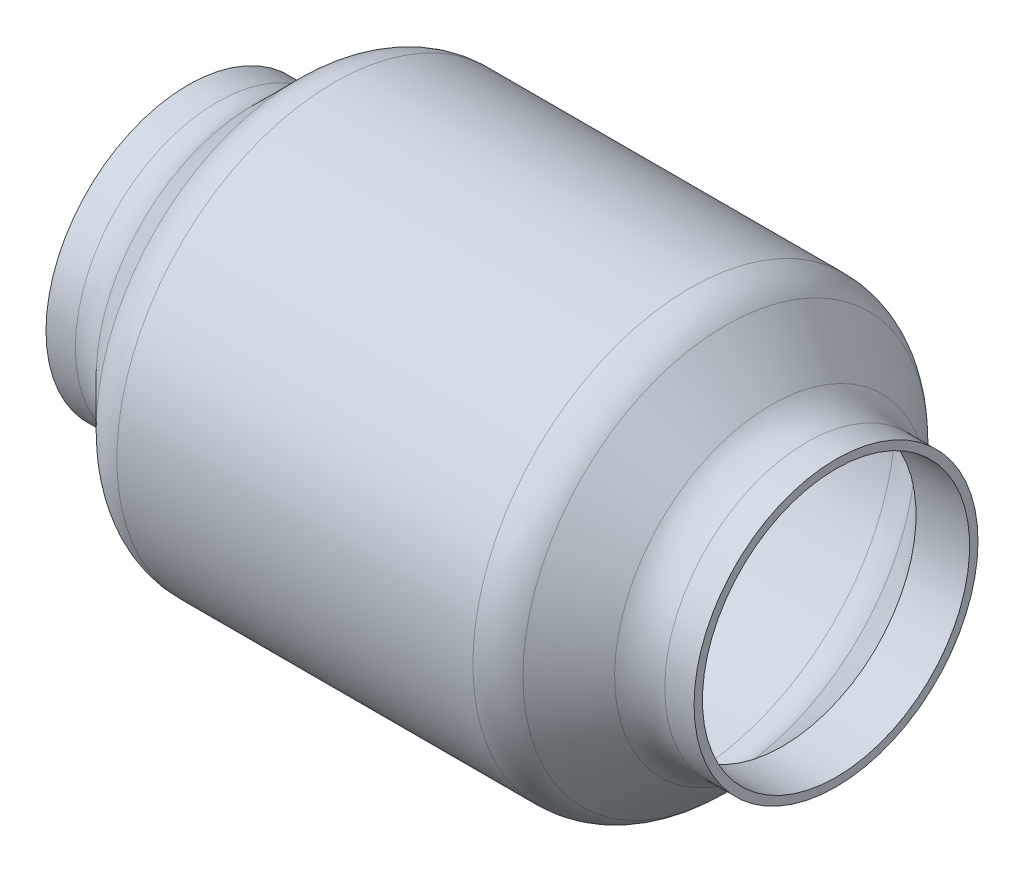
from build123d import *


with BuildPart() as part:
    # Sketch1 → Revolve1 (revolve)
    with BuildSketch(Plane.XY):
        with BuildLine():
            Line((-123.19, 53.975), (-123.19, 50.8))
            Line((-123.19, 50.8), (-102.824871939, 50.8))
            Line((-102.824871939, 50.8), (-79.829487758, 73.795384182))
            ThreePointArc((-79.829487758, 73.795384182), (-73.649222963, 77.924905094), (-66.359103576, 79.375))
            Line((-66.359103576, 79.375), (66.359103576, 79.375))
            ThreePointArc((66.359103576, 79.375), (73.649222963, 77.924905094), (79.829487758, 73.795384182))
            Line((79.829487758, 73.795384182), (102.824871939, 50.8))
            Line((102.824871939, 50.8), (123.19, 50.8))
            Line((123.19, 50.8), (123.19, 53.975))
            Line((123.19, 53.975), (112.030768363, 53.975))
            ThreePointArc((112.030768363, 53.975), (104.740648977, 55.425094906), (98.560384182, 59.554615818))
            Line((98.560384182, 59.554615818), (81.144615818, 76.970384182))
            ThreePointArc((81.144615818, 76.970384182), (74.964351023, 81.099905094), (67.674231637, 82.55))
            Line((67.674231637, 82.55), (-67.674231637, 82.55))
            ThreePointArc((-67.674231637, 82.55), (-74.964351023, 81.099905094), (-81.144615818, 76.970384182))
            Line((-81.144615818, 76.970384182), (-98.560384182, 59.554615818))
            ThreePointArc((-98.560384182, 59.554615818), (-104.740648977, 55.425094906), (-112.030768363, 53.975))
            Line((-112.030768363, 53.975), (-123.19, 53.975))
        make_face()
    revolve(axis=Axis((-123.19, 0, 0), (1, 0, 0)))


solid = part.part
